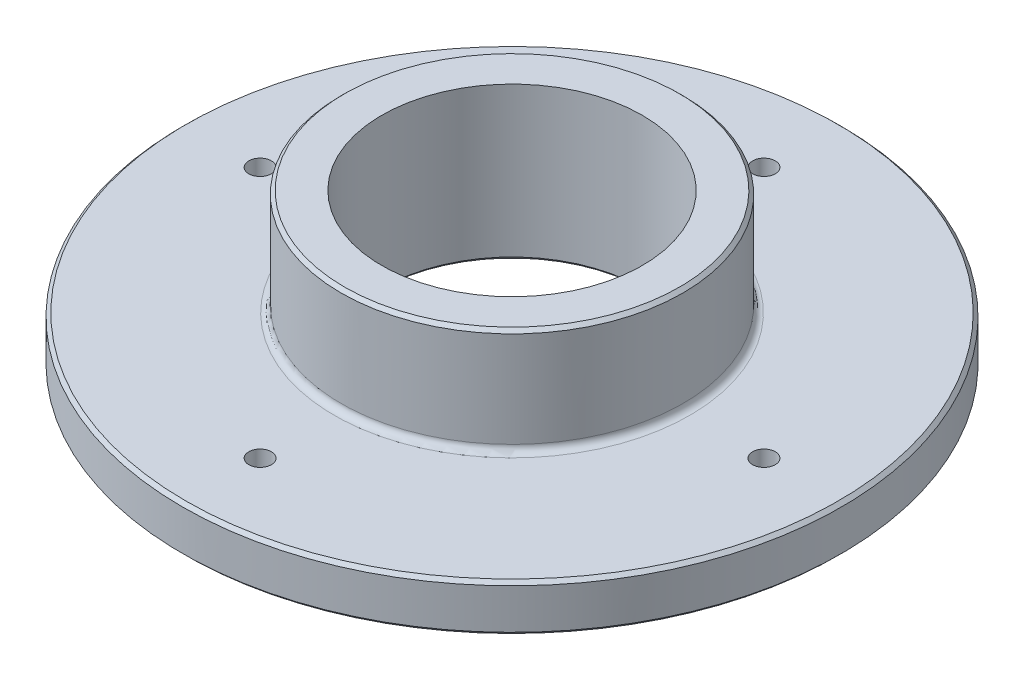
from build123d import *

# Parameters (mm, degrees)
CHANFRO1_SIZE               = 1
FURO_COM_FOLGA_DE_M61_D     = 6.6
FURO_COM_FOLGA_DE_M61_DEPTH = 23.799
FURO_COM_FOLGA_DE_M61_TIP   = 1.982840043


with BuildPart() as part:
    # Esboço1 → Revolução1 (revolve)
    with BuildSketch(Plane.XY):
        with BuildLine():
            Line((96.4, 0), (96.4, 13.8))
            Line((96.4, 13.8), (52, 13.8))
            ThreePointArc((52, 13.8), (50.585786438, 14.385786438), (50, 15.8))
            Line((50, 15.8), (50, 44.8))
            Line((50, 44.8), (38.1, 44.8))
            Line((38.1, 44.8), (38.1, 0))
            Line((38.1, 0), (96.4, 0))
        make_face()
    revolve(axis=Axis((0, 0, 0), (0, 1, 0)))

    # Chanfro1
    chanfro1_edges = [part.edges().sort_by_distance(p)[0] for p in [
        (-96.4, 0, 0),
        (-96.4, 13.8, 0),
        (-50, 44.8, 0),
        (-38.1, 0, 0),
    ]]
    chamfer(chanfro1_edges, length=CHANFRO1_SIZE)

    # Furo com folga de M61
    with Locations(Plane.ZX.offset(13.8)):
        with Locations((0, 73.7), (73.7, 0), (0, -73.7), (-73.7, 0), (0, 0)):
            Hole(FURO_COM_FOLGA_DE_M61_D / 2, depth=FURO_COM_FOLGA_DE_M61_DEPTH)
            with Locations((0, 0, -(FURO_COM_FOLGA_DE_M61_DEPTH + FURO_COM_FOLGA_DE_M61_TIP / 2))):  # 118° drill point
                Cone(0, FURO_COM_FOLGA_DE_M61_D / 2, FURO_COM_FOLGA_DE_M61_TIP, mode=Mode.SUBTRACT)


solid = part.part
